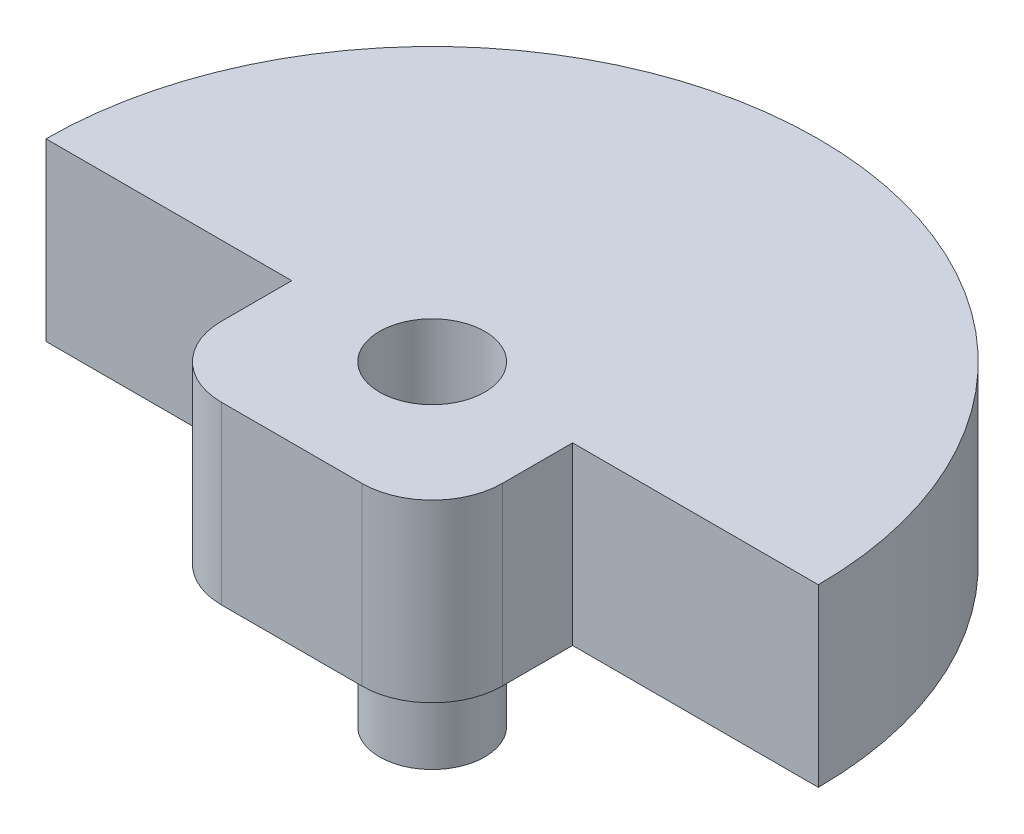
from build123d import *

# Parameters (mm, degrees)
SKETCH2_R           = 0.375
BOSS_EXTRUDE1_DEPTH = 1
BOSS_EXTRUDE2_DEPTH = 1.25
FILLET1_R           = 0.5


with BuildPart() as part:
    # Sketch2 → Boss-Extrude1 (new body)
    with BuildSketch(Plane(origin=(0, 0, 0), x_dir=(1, 0, 0), z_dir=(0, 1, 0))):
        Circle(SKETCH2_R)
    extrude(amount=BOSS_EXTRUDE1_DEPTH)


with BuildPart() as body_2:
    # Sketch3 → Boss-Extrude2 (new body)
    with BuildSketch(Plane(origin=(0, 1, 0), x_dir=(1, 0, 0), z_dir=(0, 1, 0))):
        with BuildLine():
            ThreePointArc((2.75, 0), (0, 2.75), (-2.75, 0))
            Line((-2.75, 0), (-1, 0))
            Line((-1, 0), (-0.375, 0))
            ThreePointArc((-0.375, 0), (0, 0.375), (0.375, 0))
            Line((0.375, 0), (1, 0))
            Line((1, 0), (2.75, 0))
        make_face()
        with BuildLine():
            Line((-0.375, 0), (-1, 0))
            Line((-1, 0), (-1, -1))
            Line((-1, -1), (1, -1))
            Line((1, -1), (1, 0))
            Line((1, 0), (0.375, 0))
            ThreePointArc((0.375, 0), (0, -0.375), (-0.375, 0))
        make_face()
    extrude(amount=BOSS_EXTRUDE2_DEPTH)

    # Fillet1
    fillet1_edges = [body_2.edges().sort_by_distance(p)[0] for p in [
        (1, 1.625, 1),
        (-1, 1.625, 1),
    ]]
    fillet(fillet1_edges, radius=FILLET1_R)


solid = Compound([part.part, body_2.part])
